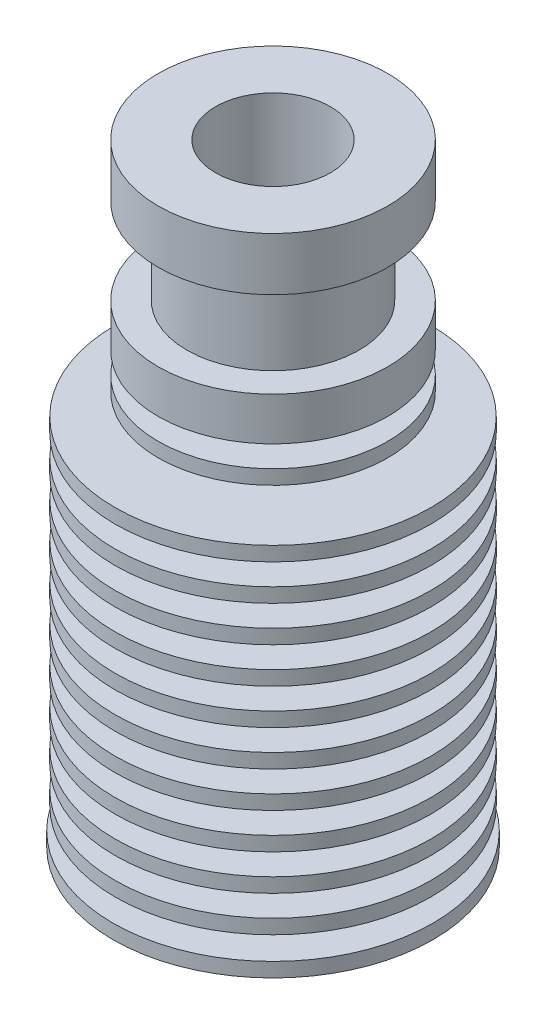
from build123d import *

# Parameters (mm, degrees)
SKETCH2_W                 = 5
SKETCH2_H                 = 1.5
LPATTERN1_COUNT           = 10
LPATTERN1_PITCH           = 2.5
M7X1_0_TAPPED_HOLE1_D     = 6
M7X1_0_TAPPED_HOLE1_DEPTH = 15.1
M7X1_0_TAPPED_HOLE1_TIP   = 1.802581857


with BuildPart() as part:
    # Sketch1 → Revolve1 (revolve)
    with BuildSketch(Plane.XY):
        Polygon((0, 42.7), (0, 0), (11.15, 0), (11.15, 1), (11, 1), (11, 26), (3.5, 26), (3.5, 27.5), (8, 27.5), (8, 28.5), (3.5, 28.5), (3.5, 30), (8, 30), (8, 33), (6, 33), (6, 39), (8, 39), (8, 42.7), align=None)
    revolve(axis=Axis((0, 0, 0), (0, -1, 0)))

    # Sketch2 → Cut-Revolve1 (revolve, cut)
    with BuildSketch(Plane.XY):
        with Locations((8.5, 1.75)):
            Rectangle(SKETCH2_W, SKETCH2_H)
    cut_revolve1 = revolve(axis=Axis((0, 0, 0), (0, 1, 0)), mode=Mode.SUBTRACT)

    # LPattern1: Cut-Revolve1 ×10
    with Locations(*[(0, i * LPATTERN1_PITCH, 0) for i in range(1, LPATTERN1_COUNT)]):
        add(cut_revolve1, mode=Mode.SUBTRACT)

    # Sketch3 → Cut-Revolve2 (revolve, cut)
    with BuildSketch(Plane.XY):
        Polygon((0, 42.7), (0, 0), (2.1, 0), (2.1, 34.3), (4, 36.2), (4, 42.7), align=None)
    revolve(axis=Axis((0, 42.7, 0), (0, -1, 0)), mode=Mode.SUBTRACT)

    # M7x1.0 Tapped Hole1
    with Locations(Plane(origin=(0, 0, 0), x_dir=(-1, 0, 0), z_dir=(0, -1, 0))):
        with Locations((0, 0)):
            Hole(M7X1_0_TAPPED_HOLE1_D / 2, depth=M7X1_0_TAPPED_HOLE1_DEPTH)
            with Locations((0, 0, -(M7X1_0_TAPPED_HOLE1_DEPTH + M7X1_0_TAPPED_HOLE1_TIP / 2))):  # 118° drill point
                Cone(0, M7X1_0_TAPPED_HOLE1_D / 2, M7X1_0_TAPPED_HOLE1_TIP, mode=Mode.SUBTRACT)


solid = part.part
